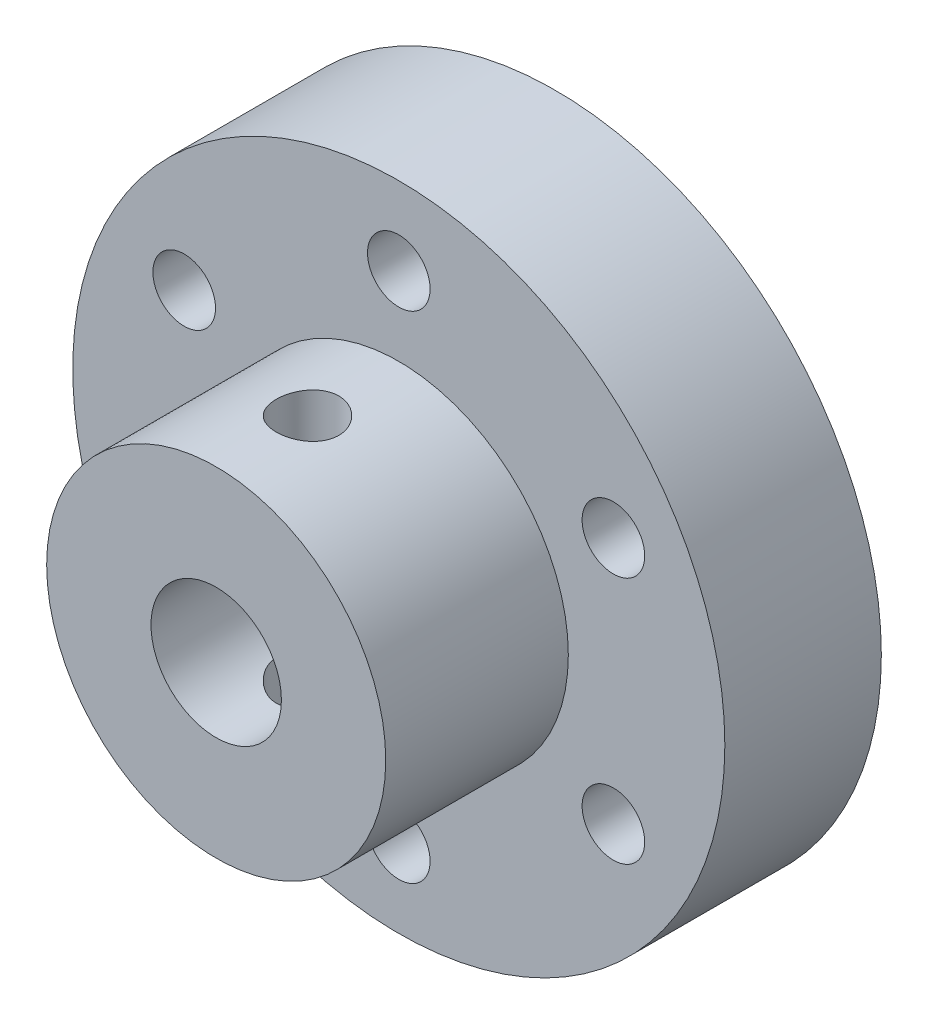
from build123d import *

# Parameters (mm, degrees)
SKETCH2_R               = 12.5
BOSS_EXTRUDE1_DEPTH     = 6
SKETCH3_R               = 6.5
SKETCH3_R_2             = 2.5
BOSS_EXTRUDE2_DEPTH     = 7
CUT_EXTRUDE1_DEPTH      = 25
CUT_EXTRUDE1_DEPTH_BACK = 25
SKETCH4_R               = 1.2
SKETCH5_R               = 1.2
CUT_EXTRUDE2_DEPTH      = 25
CIRPATTERN1_COUNT       = 6


with BuildPart() as part:
    # Sketch2 → Boss-Extrude1 (new body)
    with BuildSketch(Plane.XY):
        Circle(SKETCH2_R)
    extrude(amount=BOSS_EXTRUDE1_DEPTH)

    # Sketch3 → Boss-Extrude2 (add)
    with BuildSketch(Plane.XY.offset(6)):
        Circle(SKETCH3_R)
        Circle(SKETCH3_R_2, mode=Mode.SUBTRACT)
    extrude(amount=BOSS_EXTRUDE2_DEPTH)

    # Sketch4 → Cut-Extrude1 (cut, two sides: drawn at the far end of the back side and taken through both)
    with BuildSketch(Plane(origin=(0, 0, 0), x_dir=(1, 0, 0), z_dir=(0, 1, 0)).offset(-CUT_EXTRUDE1_DEPTH_BACK)):
        with Locations((0, -9.5)):
            Circle(SKETCH4_R)
    extrude(amount=CUT_EXTRUDE1_DEPTH + CUT_EXTRUDE1_DEPTH_BACK, mode=Mode.SUBTRACT)

    # Sketch5 → Cut-Extrude2 (cut, symmetric)
    with BuildSketch(Plane.XY.offset(6)):
        with Locations((0, 9.5)):
            Circle(SKETCH5_R)
    cut_extrude2 = extrude(amount=CUT_EXTRUDE2_DEPTH, both=True, mode=Mode.SUBTRACT)

    # CirPattern1: Cut-Extrude2 ×6 about axis
    cirpattern1_axis = Axis((0, 0, -0.6), (0, 0, 1))
    for i in range(1, CIRPATTERN1_COUNT):
        add(cut_extrude2.rotate(cirpattern1_axis, i * 360 / CIRPATTERN1_COUNT), mode=Mode.SUBTRACT)


solid = part.part
